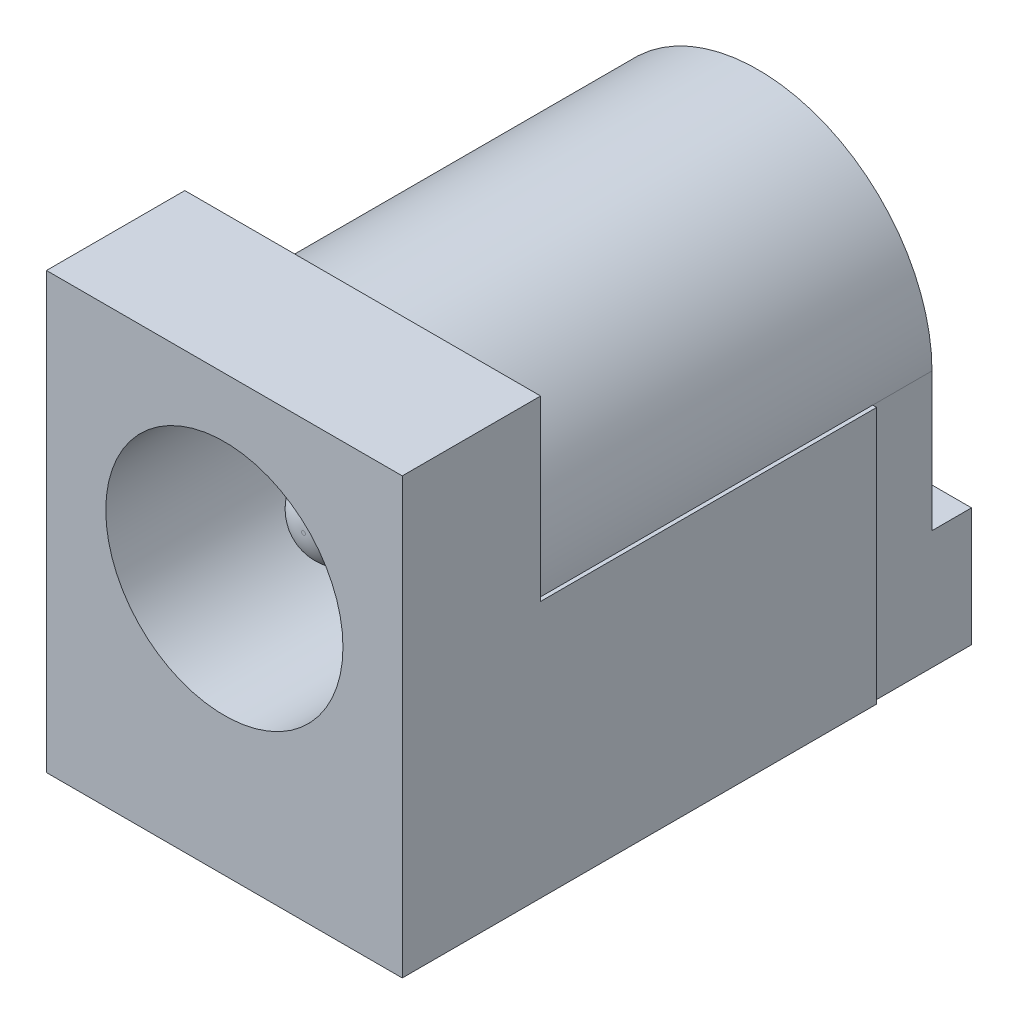
from build123d import *

# Parameters (mm, degrees)
SKETCH1_W               = 14.5
SKETCH1_H               = 11
BOSS_EXTRUDE1_DEPTH     = 9
CUT_EXTRUDE1_DEPTH      = 21.303940504
CUT_EXTRUDE1_DEPTH_BACK = 11
SKETCH5_W               = 2.5
SKETCH5_H               = 6.5
CUT_EXTRUDE2_DEPTH      = 0.1
SKETCH6_W               = 2.5
SKETCH6_H               = 6.5
CUT_EXTRUDE3_DEPTH      = 0.1
CUT_EXTRUDE4_START      = -1
CUT_EXTRUDE4_DEPTH      = 1
SKETCH8_W               = 2.9
SKETCH8_H               = 3
BOSS_EXTRUDE2_DEPTH     = 1
SKETCH9_R               = 3
CUT_EXTRUDE5_DEPTH      = 12
BOSS_EXTRUDE4_DEPTH     = 0.4
FILLET1_R               = 1.4
SKETCH12_R              = 0.8
CUT_EXTRUDE6_DEPTH      = 0.4
SKETCH13_R              = 1.5
SKETCH13_R_2            = 1
BOSS_EXTRUDE6_DEPTH     = 0.2
BOSS_EXTRUDE6_DRAFT     = 35
SKETCH16_W              = 2.5
SKETCH16_H              = 0.4
BOSS_EXTRUDE7_DEPTH     = 3.5
SKETCH18_R              = 0.8
CUT_EXTRUDE8_DEPTH      = 0.4
FILLET2_R               = 1.1
SKETCH19_R              = 1.05
BOSS_EXTRUDE8_DEPTH     = 10
FILLET3_R               = 1


with BuildPart() as part:
    # Sketch1 → Boss-Extrude1 (new body)
    with BuildSketch(Plane(origin=(0, 0, 0), x_dir=(0, 0, -1), z_dir=(1, 0, 0))):
        with Locations((7.25, 5.5)):
            Rectangle(SKETCH1_W, SKETCH1_H)
    extrude(amount=BOSS_EXTRUDE1_DEPTH)

    # Sketch2 → Cut-Extrude1 (cut, two sides: drawn at the far end of the back side and taken through both)
    with BuildSketch(Plane(origin=(0, 0, -14.5), x_dir=(-1, 0, 0), z_dir=(0, 0, -1)).offset(-CUT_EXTRUDE1_DEPTH_BACK)):
        with BuildLine():
            Line((-9, 6.5), (-8.9, 6.5))
            ThreePointArc((-8.9, 6.5), (-4.5, 10.9), (-0.1, 6.5))
            Line((-0.1, 6.5), (0, 6.5))
            Line((0, 6.5), (0, 11))
            Line((0, 11), (-9, 11))
            Line((-9, 11), (-9, 6.5))
        make_face()
    extrude(amount=CUT_EXTRUDE1_DEPTH + CUT_EXTRUDE1_DEPTH_BACK, mode=Mode.SUBTRACT)

    # Sketch5 → Cut-Extrude2 (cut)
    with BuildSketch(Plane.ZY):
        with Locations((-13.25, 3.25)):
            Rectangle(SKETCH5_W, SKETCH5_H)
    extrude(amount=-CUT_EXTRUDE2_DEPTH, mode=Mode.SUBTRACT)

    # Sketch6 → Cut-Extrude3 (cut)
    with BuildSketch(Plane(origin=(9, 0, 0), x_dir=(0, 0, -1), z_dir=(1, 0, 0))):
        with Locations((13.25, 3.25)):
            Rectangle(SKETCH6_W, SKETCH6_H)
    extrude(amount=-CUT_EXTRUDE3_DEPTH, mode=Mode.SUBTRACT)

    # Sketch7 → Cut-Extrude4 (cut)
    with BuildSketch(Plane(origin=(0, 0, -14.5), x_dir=(-1, 0, 0), z_dir=(0, 0, -1)).offset(CUT_EXTRUDE4_START)):
        with BuildLine():
            Line((-8.9, 6.5), (-8.9, 0))
            Line((-8.9, 0), (-0.1, 0))
            Line((-0.1, 0), (-0.1, 6.5))
            ThreePointArc((-0.1, 6.5), (-4.5, 10.9), (-8.9, 6.5))
        make_face()
    extrude(amount=CUT_EXTRUDE4_DEPTH, mode=Mode.SUBTRACT)

    # Sketch8 → Boss-Extrude2 (add)
    with BuildSketch(Plane(origin=(0, 0, -13.5), x_dir=(-1, 0, 0), z_dir=(0, 0, -1))):
        with Locations((-7.45, 1.5)):
            Rectangle(SKETCH8_W, SKETCH8_H)
        with Locations((-1.55, 1.5)):
            Rectangle(SKETCH8_W, SKETCH8_H)
    extrude(amount=BOSS_EXTRUDE2_DEPTH)

    # Sketch9 → Cut-Extrude5 (cut)
    with BuildSketch(Plane.XY):
        with Locations((4.5, 6.5)):
            Circle(SKETCH9_R)
    extrude(amount=-CUT_EXTRUDE5_DEPTH, mode=Mode.SUBTRACT)



with BuildPart() as body_2:
    # Sketch10 → Boss-Extrude4 (new body)
    with BuildSketch(Plane(origin=(0, 0, -13.5), x_dir=(-1, 0, 0), z_dir=(0, 0, -1))):
        with BuildLine():
            Line((-6, 0), (-6, 5.317587213))
            ThreePointArc((-6, 5.317587213), (-4.501820172, 8.409999133), (-2.997749118, 5.320448268))
            Line((-2.997749118, 5.320448268), (-2.997749118, 0))
            Line((-2.997749118, 0), (-2.997749118, -3.5))
            Line((-2.997749118, -3.5), (-6, -3.5))
            Line((-6, -3.5), (-6, 0))
        make_face()
    extrude(amount=BOSS_EXTRUDE4_DEPTH)


with BuildPart() as part_1:
    add(part.part)

    add(body_2.part)  # Boss-Extrude5 merges body 2
    # Boss-Extrude5 cone 1 section (through the dimple's axis) → Boss-Extrude5 (revolve)
    with BuildSketch(Plane(origin=(4.5, 1.5, -13.9), x_dir=(0, -1, 0), z_dir=(1, 0, 0))):
        Polygon((0, 0), (0.5, 0), (0, 0.08816349), align=None)
    revolve(axis=Axis((4.5, 1.5, -13.9), (0, 0, -1)))

    # Fillet1
    fillet1_edges = [part_1.edges().sort_by_distance(p)[0] for p in [
        (2.997749118, -3.5, -13.7),
        (6, -3.5, -13.7),
    ]]
    fillet(fillet1_edges, radius=FILLET1_R)

    # Sketch12 → Cut-Extrude6 (cut)
    with BuildSketch(Plane(origin=(0, 0, -13.9), x_dir=(-1, 0, 0), z_dir=(0, 0, -1))):
        with Locations((-4.474664636, -2)):
            Circle(SKETCH12_R)
    extrude(amount=-CUT_EXTRUDE6_DEPTH, mode=Mode.SUBTRACT)

    # Cut-Extrude7 cone 1 section (through the dimple's axis) → Cut-Extrude7 (revolve, cut)
    with BuildSketch(Plane(origin=(4.504178443, 6.5, -13.9), x_dir=(0, 1, 0), z_dir=(1, 0, 0))):
        Polygon((0, 0), (0.8, 0), (0, 0.069990931), align=None)
    revolve(axis=Axis((4.504178443, 6.5, -13.9), (0, 0, 1)), mode=Mode.SUBTRACT)

    # Sketch16 → Boss-Extrude7 (add)
    with BuildSketch(Plane.XZ):
        with Locations((4.5, -7.9)):
            Rectangle(SKETCH16_W, SKETCH16_H)
    extrude(amount=BOSS_EXTRUDE7_DEPTH)

    # Sketch18 → Cut-Extrude8 (cut)
    with BuildSketch(Plane.XY.offset(-7.7)):
        with Locations((4.5, -2)):
            Circle(SKETCH18_R)
    extrude(amount=-CUT_EXTRUDE8_DEPTH, mode=Mode.SUBTRACT)

    # Fillet2
    fillet2_edges = [part_1.edges().sort_by_distance(p)[0] for p in [
        (3.25, -3.5, -7.9),
        (5.75, -3.5, -7.9),
    ]]
    fillet(fillet2_edges, radius=FILLET2_R)

    # Sketch19 → Boss-Extrude8 (add)
    with BuildSketch(Plane.XY.offset(-12)):
        with Locations((4.5, 6.5)):
            Circle(SKETCH19_R)
    extrude(amount=BOSS_EXTRUDE8_DEPTH)

    # Fillet3
    fillet3_edges = [part_1.edges().sort_by_distance(p)[0] for p in [
        (3.45, 6.5, -2),
    ]]
    fillet(fillet3_edges, radius=FILLET3_R)


with BuildPart() as body_2_2:
    # Sketch13 → Boss-Extrude6 (with draft: the straight prism first)
    with BuildSketch(Plane(origin=(0, 0, -13.9), x_dir=(-1, 0, 0), z_dir=(0, 0, -1))):
        with Locations((-4.504178443, 6.5)):
            Circle(SKETCH13_R)
        with Locations((-4.504178443, 6.5)):
            Circle(SKETCH13_R_2, mode=Mode.SUBTRACT)
    extrude(amount=BOSS_EXTRUDE6_DEPTH)
    # Boss-Extrude6: the draft: its side faces are tilted about the plane it starts from
    boss_extrude6_sides = [body_2_2.faces().sort_by_distance(p)[0] for p in [
        (6.004178443, 6.5, -14),
        (5.504178443, 6.5, -14),
    ]]
    draft(boss_extrude6_sides, Plane(origin=(0, 0, -13.9), x_dir=(-1, 0, 0), z_dir=(0, 0, -1)), BOSS_EXTRUDE6_DRAFT)


solid = Compound([part_1.part, body_2_2.part])
